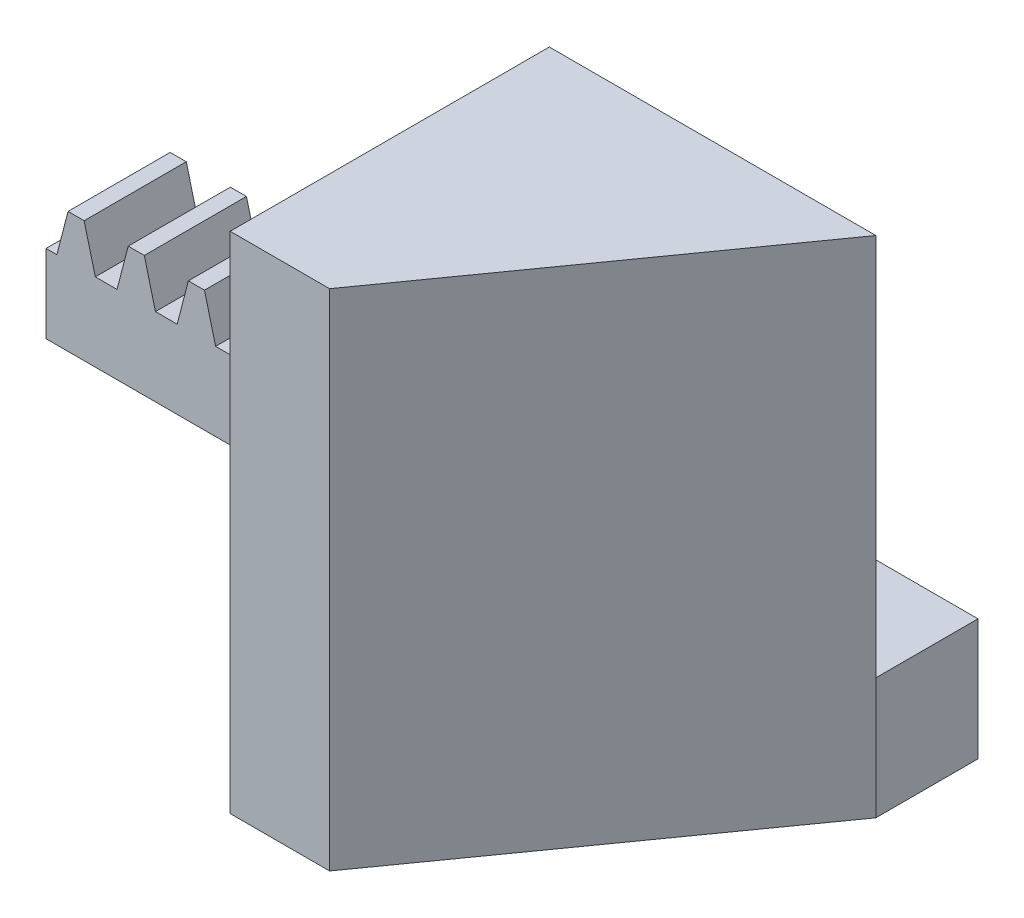
from build123d import *

# Parameters (mm, degrees)
BLANKSKE_W          = 50
BLANKSKE_H          = 9.5
BLANK_DEPTH         = 8
TOOTHCUTSIM_DEPTH   = 52.519413817
TEETHCUTS_COUNT     = 11
TEETHCUTS_PITCH     = 4.712388975
SKETCH3_W           = 8
SKETCH3_H           = 9.5
BOSS_EXTRUDE2_DEPTH = 15
BOSS_EXTRUDE5_DEPTH = 39.5


with BuildPart() as part:
    # BlankSke → Blank (new body)
    with BuildSketch(Plane.XY):
        with Locations((25, 4.75)):
            Rectangle(BLANKSKE_W, BLANKSKE_H)
    extrude(amount=-BLANK_DEPTH)

    # TooCutSkeSim → ToothCutSim (cut, through all)
    with BuildSketch(Plane.XY):
        Polygon((0.852189273, 6.125), (-0.852189273, 6.125), (-1.731592507, 9.5254), (1.731592507, 9.5254), align=None)
    toothcutsim = extrude(amount=-TOOTHCUTSIM_DEPTH, mode=Mode.SUBTRACT)

    # TeethCuts: ToothCutSim ×11
    with Locations(*[(i * TEETHCUTS_PITCH, 0, 0) for i in range(1, TEETHCUTS_COUNT)]):
        add(toothcutsim, mode=Mode.SUBTRACT)

    # Sketch3 → Boss-Extrude2 (add)
    with BuildSketch(Plane(origin=(50, 0, 0), x_dir=(0, 0, -1), z_dir=(1, 0, 0))):
        with Locations((4, 4.75)):
            Rectangle(SKETCH3_W, SKETCH3_H)
    extrude(amount=BOSS_EXTRUDE2_DEPTH)

    # Sketch7 → Boss-Extrude5 (add)
    with BuildSketch(Plane(origin=(0, 0, 0), x_dir=(1, 0, 0), z_dir=(0, 1, 0))):
        Polygon((65, 0), (39.42413542, 0), (39.42413542, -25), (47.21206771, -25), align=None)
    extrude(amount=BOSS_EXTRUDE5_DEPTH)


solid = part.part
